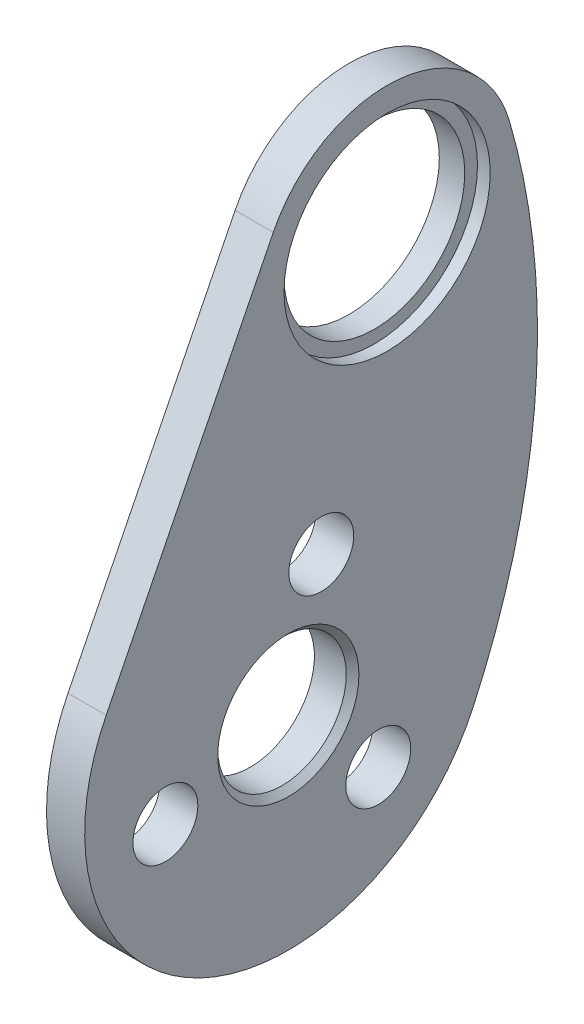
from build123d import *

# Parameters (mm, degrees)
EXTRUDE_1_DEPTH          = 3
SKETCH_2_R               = 7.1
SKETCH_2_R_2             = 5.05
CUT_EXTRUDE_1_DEPTH      = 10
SKETCH_3_R               = 2.55
CUT_EXTRUDE_2_DEPTH      = 10
PATTERN_CIRCULAR_1_COUNT = 3
CHAMFER_1_SIZE           = 0.5
SKETCH_4_R               = 8.1
CUT_EXTRUDE_3_DEPTH      = 1


with BuildPart() as part:
    # 草图1 → 凸台-拉伸1 (new body)
    with BuildSketch(Plane(origin=(0, 0, 0), x_dir=(0, 0, -1), z_dir=(1, 0, 0))):
        with BuildLine():
            ThreePointArc((6.766526321, -35.674580026), (11.667792815, -16.687604516), (9.596471541, 2.812069339))
            ThreePointArc((9.596471541, 2.812069339), (0.889352151, 9.960374127), (-8.946463525, 4.467750037))
            Line((-8.946463525, 4.467750037), (-22.078912993, -21.829374729))
            ThreePointArc((-22.078912993, -21.829374729), (-14.688022315, -43.402261843), (6.766526321, -35.674580026))
        make_face()
    extrude(amount=EXTRUDE_1_DEPTH)

    # 草图2 → 切除-拉伸1 (cut)
    with BuildSketch(Plane.ZY):
        Circle(SKETCH_2_R)
        with Locations((7.764571353, -28.977774789)):
            Circle(SKETCH_2_R_2)
    extrude(amount=-CUT_EXTRUDE_1_DEPTH, mode=Mode.SUBTRACT)

    # 草图3 → 切除-拉伸2 (cut)
    with BuildSketch(Plane.ZY):
        with Locations((5.176380902, -19.318516526)):
            Circle(SKETCH_3_R)
    cut_extrude_2 = extrude(amount=-CUT_EXTRUDE_2_DEPTH, mode=Mode.SUBTRACT)

    # 阵列(圆周)1: 切除-拉伸2 ×3 about axis
    pattern_circular_1_axis = Axis((0, -28.977774789, 7.764571353), (1, 0, 0))
    for i in range(1, PATTERN_CIRCULAR_1_COUNT):
        add(cut_extrude_2.rotate(pattern_circular_1_axis, i * 360 / PATTERN_CIRCULAR_1_COUNT), mode=Mode.SUBTRACT)

    # 倒角1
    chamfer_1_edges = [part.edges().sort_by_distance(p)[0] for p in [
        (3, -28.977774789, 2.714571353),
    ]]
    chamfer(chamfer_1_edges, length=CHAMFER_1_SIZE)

    # 草图4 → 切除-拉伸3 (cut)
    with BuildSketch(Plane.ZY.offset(-3)):
        Circle(SKETCH_4_R)
    extrude(amount=CUT_EXTRUDE_3_DEPTH, mode=Mode.SUBTRACT)


solid = part.part
